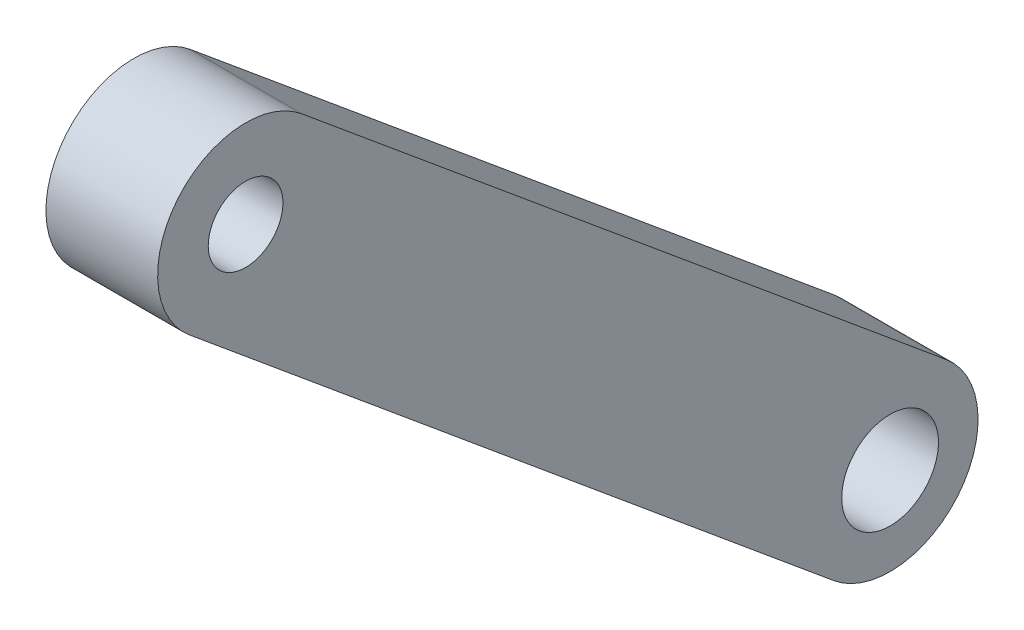
from build123d import *

# Parameters (mm, degrees)
SKETCH1_R           = 2.2
SKETCH1_R_2         = 1.7
BOSS_EXTRUDE1_DEPTH = 5.08


with BuildPart() as part:
    # Sketch1 → Boss-Extrude1 (new body)
    with BuildSketch(Plane(origin=(17.497777778, 0, 0), x_dir=(0, 0, -1), z_dir=(1, 0, 0))):
        with BuildLine():
            Line((-499.600738517, 24.004018568), (-470.286926412, -0.333409807))
            ThreePointArc((-470.286926412, -0.333409807), (-464.654250247, 0.189045178), (-465.176705231, 5.821721344))
            Line((-465.176705231, 5.821721344), (-494.490517336, 30.159149718))
            ThreePointArc((-494.490517336, 30.159149718), (-500.123193502, 29.636694733), (-499.600738517, 24.004018568))
        make_face()
        with Locations((-467.731815822, 2.744155769)):
            Circle(SKETCH1_R, mode=Mode.SUBTRACT)
        with Locations((-497.045627927, 27.081584143)):
            Circle(SKETCH1_R_2, mode=Mode.SUBTRACT)
    extrude(amount=-BOSS_EXTRUDE1_DEPTH)


solid = part.part
